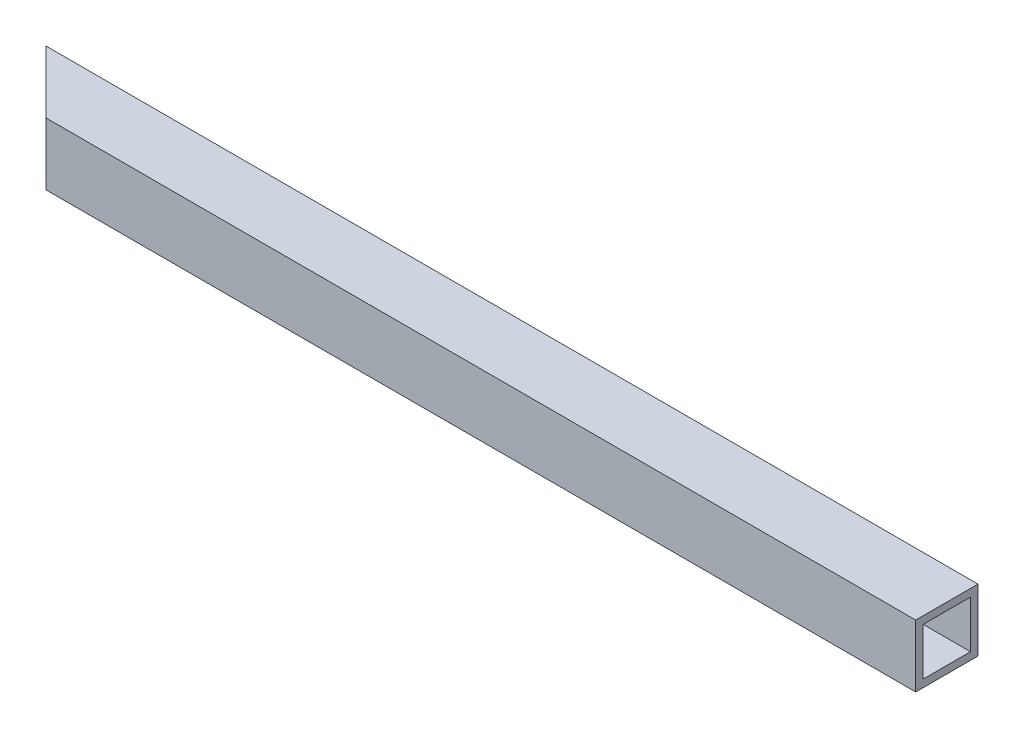
from build123d import *

# Parameters (mm, degrees)
BOSS_EXTRUDE1_DEPTH = 25
SHELL1_T            = -3


with BuildPart() as part:
    # Sketch1 → Boss-Extrude1 (new body)
    with BuildSketch(Plane(origin=(0, 0, 0), x_dir=(1, 0, 0), z_dir=(0, 1, 0))):
        Polygon((-174.5, 170.560948081), (174.5, 170.560948081), (174.5, 195.560948081), (-199.5, 195.560948081), align=None)
    extrude(amount=BOSS_EXTRUDE1_DEPTH)

    # Shell1
    shell1_openings = [part.faces().sort_by_distance(p)[0] for p in [
        (174.5, 12.5, -183.060948081),
        (-187, 12.5, -183.060948081),
    ]]
    offset(amount=SHELL1_T, openings=shell1_openings, kind=Kind.INTERSECTION)


solid = part.part
